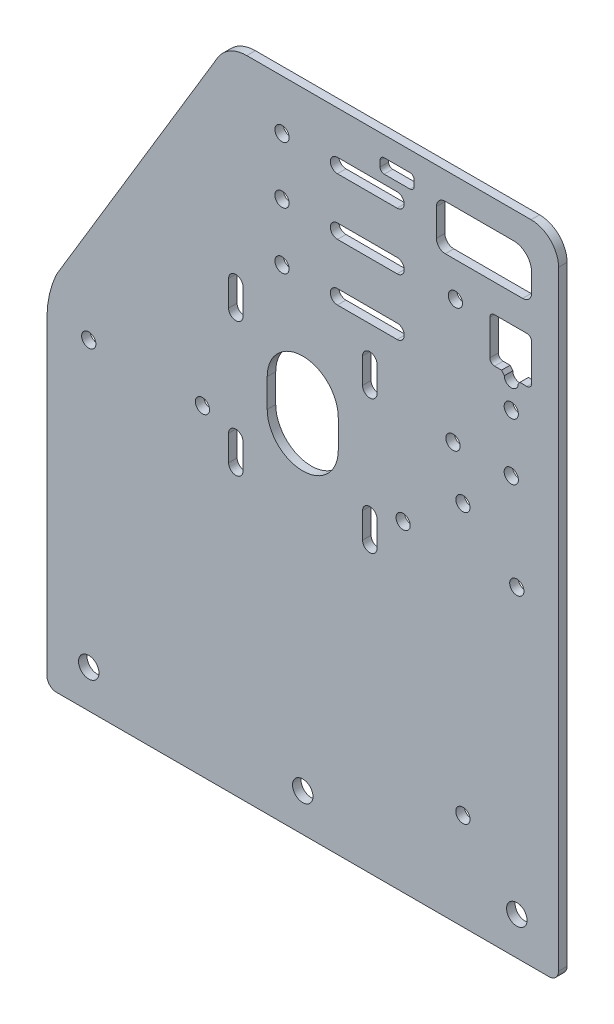
from build123d import *

# Parameters (mm, degrees)
MODEL_R             = 3.6
MODEL_R_2           = 2.5
BOSS_EXTRUDE1_DEPTH = 3


with BuildPart() as part:
    # Model → Boss-Extrude1 (new body)
    with BuildSketch(Plane.XY):
        with BuildLine():
            Line((-86.64, 0), (86.64, 0))
            ThreePointArc((86.64, 0), (89.015878785, 0.984121215), (90, 3.36))
            Line((90, 3.36), (90, 217.83))
            ThreePointArc((90, 217.83), (87.167722574, 224.667722574), (80.33, 227.5))
            Line((80.33, 227.5), (-19.67, 227.5))
            ThreePointArc((-19.67, 227.5), (-25.584006957, 225.942971908), (-29.964579281, 221.67560728))
            Line((-29.964579281, 221.67560728), (-86.618767522, 127.387204203))
            ThreePointArc((-86.618767522, 127.387204203), (-89.126906327, 120.031940724), (-90, 112.31))
            Line((-90, 112.31), (-90, 3.36))
            ThreePointArc((-90, 3.36), (-89.015878785, 0.984121215), (-86.64, 0))
        make_face()
        with Locations((-75.285, 13.33)):
            Circle(MODEL_R, mode=Mode.SUBTRACT)
        with Locations((-7.295, 209.94)):
            Circle(MODEL_R_2, mode=Mode.SUBTRACT)
        with Locations((-7.295, 189.94)):
            Circle(MODEL_R_2, mode=Mode.SUBTRACT)
        with Locations((-7.295, 169.94)):
            Circle(MODEL_R_2, mode=Mode.SUBTRACT)
        with Locations((-35.285, 113.03)):
            Circle(MODEL_R_2, mode=Mode.SUBTRACT)
        with Locations((-75.285, 113.03)):
            Circle(MODEL_R_2, mode=Mode.SUBTRACT)
        with Locations((75.315, 13.33)):
            Circle(MODEL_R, mode=Mode.SUBTRACT)
        with Locations((0, 13.33)):
            Circle(MODEL_R, mode=Mode.SUBTRACT)
        with Locations((56.355, 34.03)):
            Circle(MODEL_R_2, mode=Mode.SUBTRACT)
        with Locations((53.705, 189.94)):
            Circle(MODEL_R_2, mode=Mode.SUBTRACT)
        with Locations((73.365, 165.98)):
            Circle(MODEL_R_2, mode=Mode.SUBTRACT)
        with Locations((73.365, 145.98)):
            Circle(MODEL_R_2, mode=Mode.SUBTRACT)
        with Locations((52.865, 145.98)):
            Circle(MODEL_R_2, mode=Mode.SUBTRACT)
        with Locations((56.355, 129.03)):
            Circle(MODEL_R_2, mode=Mode.SUBTRACT)
        with Locations((75.315, 113.03)):
            Circle(MODEL_R_2, mode=Mode.SUBTRACT)
        with Locations((35.315, 113.03)):
            Circle(MODEL_R_2, mode=Mode.SUBTRACT)
        with BuildLine():
            Line((-26.095, 100.21), (-26.095, 109.21))
            ThreePointArc((-26.095, 109.21), (-23.555, 111.75), (-21.015, 109.21))
            Line((-21.015, 109.21), (-21.015, 100.21))
            ThreePointArc((-21.015, 100.21), (-23.555, 97.67), (-26.095, 100.21))
        make_face(mode=Mode.SUBTRACT)
        with BuildLine():
            Line((-26.095, 147.35), (-26.095, 156.35))
            ThreePointArc((-26.095, 156.35), (-23.555, 158.89), (-21.015, 156.35))
            Line((-21.015, 156.35), (-21.015, 147.35))
            ThreePointArc((-21.015, 147.35), (-23.555, 144.81), (-26.095, 147.35))
        make_face(mode=Mode.SUBTRACT)
        with BuildLine():
            Line((21.045, 100.21), (21.045, 109.21))
            ThreePointArc((21.045, 109.21), (23.585, 111.75), (26.125, 109.21))
            Line((26.125, 109.21), (26.125, 100.21))
            ThreePointArc((26.125, 100.21), (23.585, 97.67), (21.045, 100.21))
        make_face(mode=Mode.SUBTRACT)
        with BuildLine():
            Line((21.045, 147.35), (21.045, 156.35))
            ThreePointArc((21.045, 156.35), (23.585, 158.89), (26.125, 156.35))
            Line((26.125, 156.35), (26.125, 147.35))
            ThreePointArc((26.125, 147.35), (23.585, 144.81), (21.045, 147.35))
        make_face(mode=Mode.SUBTRACT)
        with BuildLine():
            Line((27.205, 216.97), (27.205, 219.09))
            ThreePointArc((27.205, 219.09), (27.626766235, 220.108233765), (28.645, 220.53))
            Line((28.645, 220.53), (37.765, 220.53))
            ThreePointArc((37.765, 220.53), (38.783233765, 220.108233765), (39.205, 219.09))
            Line((39.205, 219.09), (39.205, 216.97))
            ThreePointArc((39.205, 216.97), (38.783233765, 215.951766235), (37.765, 215.53))
            Line((37.765, 215.53), (28.645, 215.53))
            ThreePointArc((28.645, 215.53), (27.626766235, 215.951766235), (27.205, 216.97))
        make_face(mode=Mode.SUBTRACT)
        with BuildLine():
            Line((76.385, 175.96), (75.817986625, 175.249714613))
            add(Edge.make_bspline(
                [(70.912013375, 175.249714613), (70.912013375, 172.796727988), (73.365, 172.796727988), (75.817986625, 172.796727988), (75.817986625, 175.249714613)],
                knots=[3.141592654, 3.141592654, 3.141592654, 4.71238898, 4.71238898, 6.283185307, 6.283185307, 6.283185307], degree=2, weights=[1, 0.707106781, 1, 0.707106781, 1]))
            Line((70.912013375, 175.249714613), (69.945, 176.461071346))
            Line((69.945, 176.461071346), (67.475, 176.461071346))
            ThreePointArc((67.475, 176.461071346), (66.301202743, 176.947274089), (65.815, 178.121071346))
            Line((65.815, 178.121071346), (65.815, 190.45))
            ThreePointArc((65.815, 190.45), (66.301202743, 191.623797257), (67.475, 192.11))
            Line((67.475, 192.11), (78.855, 192.11))
            ThreePointArc((78.855, 192.11), (80.028797257, 191.623797257), (80.515, 190.45))
            Line((80.515, 190.45), (80.515, 177.62))
            ThreePointArc((80.515, 177.62), (80.028797257, 176.446202743), (78.855, 175.96))
            Line((78.855, 175.96), (76.385, 175.96))
        make_face(mode=Mode.SUBTRACT)
        with BuildLine():
            Line((47.015, 205.17), (47.015, 214.86))
            ThreePointArc((47.015, 214.86), (47.934684707, 217.080315293), (50.155, 218))
            Line((50.155, 218), (74.165, 218))
            ThreePointArc((74.165, 218), (78.655128061, 216.140128061), (80.515, 211.65))
            Line((80.515, 211.65), (80.515, 205.17))
            ThreePointArc((80.515, 205.17), (79.595315293, 202.949684707), (77.375, 202.03))
            Line((77.375, 202.03), (50.155, 202.03))
            ThreePointArc((50.155, 202.03), (47.934684707, 202.949684707), (47.015, 205.17))
        make_face(mode=Mode.SUBTRACT)
        with BuildLine():
            Line((33.205, 167.44), (12.205, 167.44))
            ThreePointArc((12.205, 167.44), (9.705, 169.94), (12.205, 172.44))
            Line((12.205, 172.44), (33.205, 172.44))
            ThreePointArc((33.205, 172.44), (35.705, 169.94), (33.205, 167.44))
        make_face(mode=Mode.SUBTRACT)
        with BuildLine():
            Line((33.205, 187.44), (12.205, 187.44))
            ThreePointArc((12.205, 187.44), (9.705, 189.94), (12.205, 192.44))
            Line((12.205, 192.44), (33.205, 192.44))
            ThreePointArc((33.205, 192.44), (35.705, 189.94), (33.205, 187.44))
        make_face(mode=Mode.SUBTRACT)
        with BuildLine():
            Line((33.205, 207.44), (12.205, 207.44))
            ThreePointArc((12.205, 207.44), (9.705, 209.94), (12.205, 212.44))
            Line((12.205, 212.44), (33.205, 212.44))
            ThreePointArc((33.205, 212.44), (35.705, 209.94), (33.205, 207.44))
        make_face(mode=Mode.SUBTRACT)
        with BuildLine():
            Line((-12.5, 123.28), (-12.5, 133.28))
            ThreePointArc((-12.5, 133.28), (0, 145.78), (12.5, 133.28))
            Line((12.5, 133.28), (12.5, 123.28))
            ThreePointArc((12.5, 123.28), (0, 110.78), (-12.5, 123.28))
        make_face(mode=Mode.SUBTRACT)
    extrude(amount=BOSS_EXTRUDE1_DEPTH)


solid = part.part
